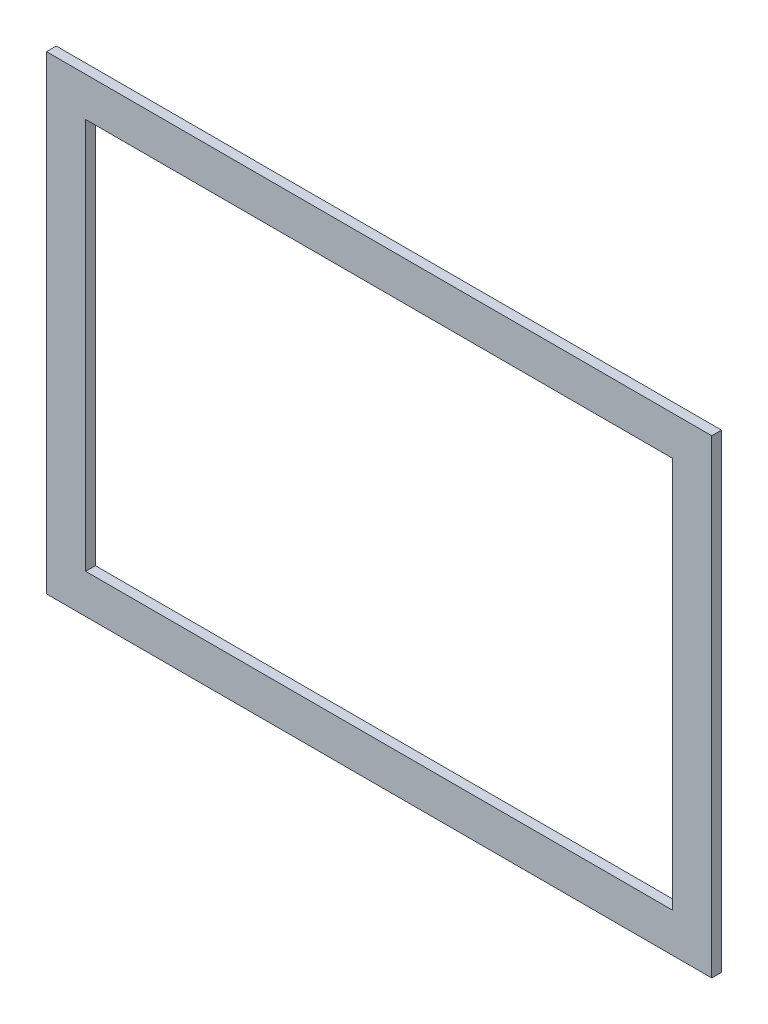
from build123d import *

# Parameters (mm, degrees)
ESQUISSE1_W        = 680
ESQUISSE1_H        = 480
ESQUISSE1_W_2      = 600
ESQUISSE1_H_2      = 400
BOSS_EXTRU_1_DEPTH = 10


with BuildPart() as part:
    # Esquisse1 → Boss.-Extru.1 (new body)
    with BuildSketch(Plane.XY):
        with Locations((-340, 240)):
            Rectangle(ESQUISSE1_W, ESQUISSE1_H)
        with Locations((-340, 240)):
            Rectangle(ESQUISSE1_W_2, ESQUISSE1_H_2, mode=Mode.SUBTRACT)
    extrude(amount=BOSS_EXTRU_1_DEPTH)


solid = part.part
